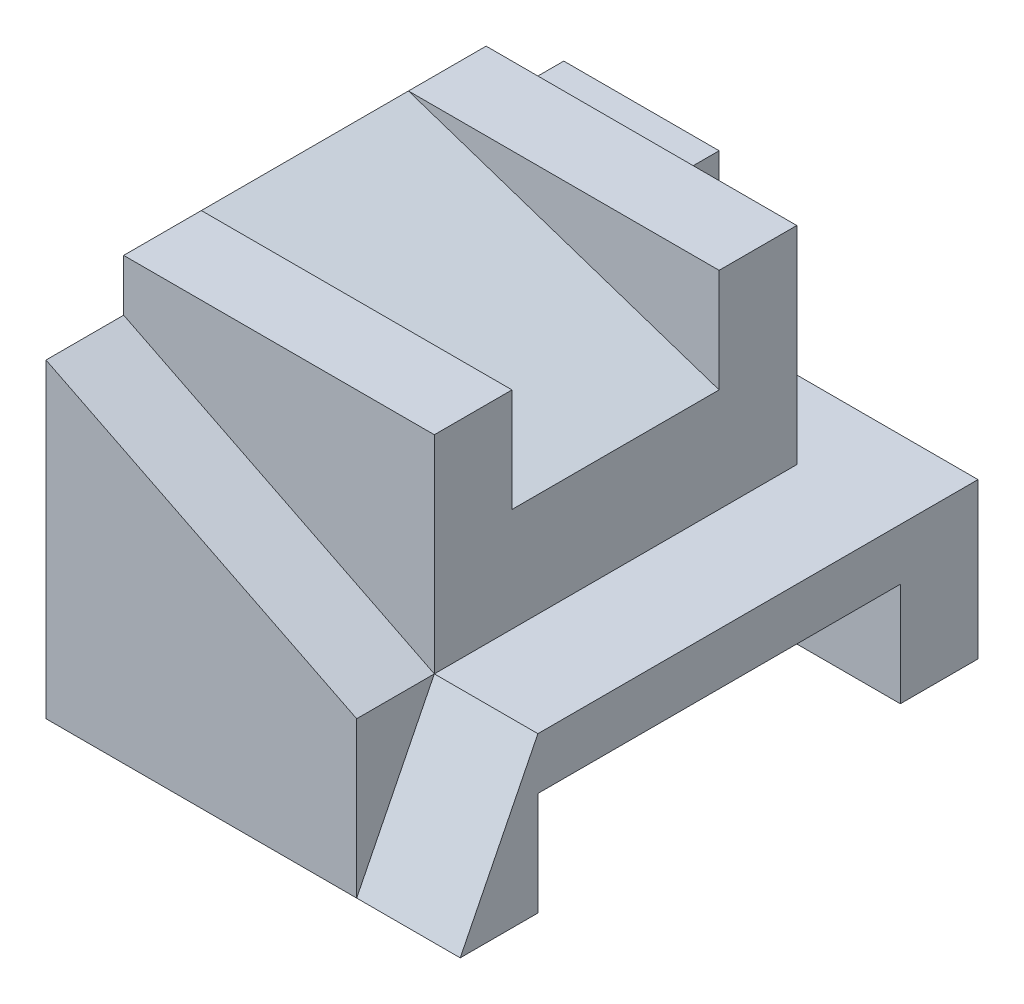
from build123d import *

# Parameters (mm, degrees)
CROQUIS1_W              = 8
CROQUIS1_H              = 10
SALIENTE_EXTRUIR1_DEPTH = 3
CROQUIS2_W              = 7
CROQUIS2_H              = 2
CORTAR_EXTRUIR1_DEPTH   = 9
CROQUIS5_W              = 6
CROQUIS5_H              = 7
SALIENTE_EXTRUIR2_DEPTH = 4
CROQUIS6_W              = 6
CROQUIS6_H              = 1.5
SALIENTE_EXTRUIR3_DEPTH = 3
CORTAR_EXTRUIR2_DEPTH   = 1.5
CORTAR_EXTRUIR3_DEPTH   = 2
CROQUIS9_W              = 3
CROQUIS9_H              = 1.5
SALIENTE_EXTRUIR4_DEPTH = 3
CROQUIS10_W             = 4
CROQUIS10_H             = 2
CORTAR_EXTRUIR4_DEPTH   = 7
SALIENTE_EXTRUIR5_DEPTH = 4


with BuildPart() as part:
    # Croquis1 → Saliente-Extruir1 (new body)
    with BuildSketch(Plane(origin=(0, 0, 0), x_dir=(1, 0, 0), z_dir=(0, 1, 0))):
        Rectangle(CROQUIS1_W, CROQUIS1_H)
    extrude(amount=SALIENTE_EXTRUIR1_DEPTH)

    # Croquis2 → Cortar-Extruir1 (cut, through all)
    with BuildSketch(Plane(origin=(4, 0, 0), x_dir=(0, 0, -1), z_dir=(1, 0, 0))):
        with Locations((0, 1)):
            Rectangle(CROQUIS2_W, CROQUIS2_H)
    extrude(amount=-CORTAR_EXTRUIR1_DEPTH, mode=Mode.SUBTRACT)

    # Croquis5 → Saliente-Extruir2 (add)
    with BuildSketch(Plane(origin=(0, 3, 0), x_dir=(1, 0, 0), z_dir=(0, 1, 0))):
        with Locations((-1, 0)):
            Rectangle(CROQUIS5_W, CROQUIS5_H)
    extrude(amount=SALIENTE_EXTRUIR2_DEPTH)

    # Croquis6 → Saliente-Extruir3 (add)
    with BuildSketch(Plane(origin=(0, 3, 0), x_dir=(1, 0, 0), z_dir=(0, 1, 0))):
        with Locations((-1, -4.25)):
            Rectangle(CROQUIS6_W, CROQUIS6_H)
    extrude(amount=SALIENTE_EXTRUIR3_DEPTH)

    # Croquis7 → Cortar-Extruir2 (cut)
    with BuildSketch(Plane.XY.offset(5)):
        Polygon((2, 3), (-4, 6), (2, 6), align=None)
    extrude(amount=-CORTAR_EXTRUIR2_DEPTH, mode=Mode.SUBTRACT)

    # Croquis8 → Cortar-Extruir3 (cut)
    with BuildSketch(Plane(origin=(4, 0, 0), x_dir=(0, 0, -1), z_dir=(1, 0, 0))):
        Polygon((-3.5, 3), (-5, 3), (-5, 0), align=None)
    extrude(amount=-CORTAR_EXTRUIR3_DEPTH, mode=Mode.SUBTRACT)

    # Croquis9 → Saliente-Extruir4 (add)
    with BuildSketch(Plane(origin=(0, 3, 0), x_dir=(1, 0, 0), z_dir=(0, 1, 0))):
        with Locations((-2.5, 4.25)):
            Rectangle(CROQUIS9_W, CROQUIS9_H)
    extrude(amount=SALIENTE_EXTRUIR4_DEPTH)

    # Croquis10 → Cortar-Extruir4 (cut, through all)
    with BuildSketch(Plane(origin=(2, 0, 0), x_dir=(0, 0, -1), z_dir=(1, 0, 0))):
        with Locations((0, 6)):
            Rectangle(CROQUIS10_W, CROQUIS10_H)
    extrude(amount=-CORTAR_EXTRUIR4_DEPTH, mode=Mode.SUBTRACT)

    # Croquis11 → Saliente-Extruir5 (add)
    with BuildSketch(Plane.XY.offset(-2)):
        Polygon((2, 5), (-4, 5), (-4, 7), align=None)
    extrude(amount=SALIENTE_EXTRUIR5_DEPTH)


solid = part.part
